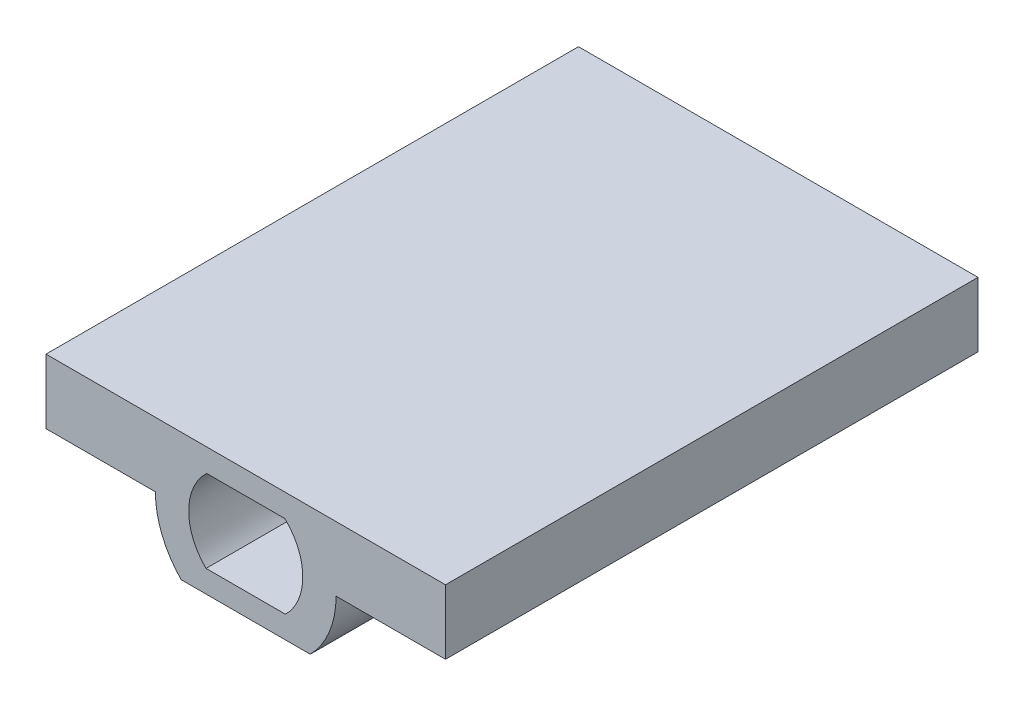
from build123d import *

# Parameters (mm, degrees)
BOSS_EXTRUDE1_DEPTH = 101.6


with BuildPart() as part:
    # Sketch1 → Boss-Extrude1 (new body)
    with BuildSketch(Plane.XY):
        with BuildLine():
            Line((-38.109310446, 0), (-38.109310446, 12.319))
            Line((-38.109310446, 12.319), (38.11716556, 12.319))
            Line((38.11716556, 12.319), (38.11716556, 0))
            Line((38.11716556, 0), (17.238227932, 0))
            ThreePointArc((17.238227932, 0), (15.959298514, -6.515926117), (12.312281561, -12.065))
            Line((12.312281561, -12.065), (12.05814004, -12.065))
            Line((12.05814004, -12.065), (-12.05814004, -12.065))
            Line((-12.05814004, -12.065), (-12.312281561, -12.065))
            ThreePointArc((-12.312281561, -12.065), (-15.959298514, -6.515926117), (-17.238227932, 0))
            Line((-17.238227932, 0), (-38.109310446, 0))
        make_face()
        with BuildLine():
            Line((-7.459501807, 7.931540852), (7.459501807, 7.931540852))
            ThreePointArc((7.459501807, 7.931540852), (10.887932539, 0.08020301), (7.575537086, -7.820789305))
            Line((7.575537086, -7.820789305), (-7.575537086, -7.820789305))
            ThreePointArc((-7.575537086, -7.820789305), (-10.887932539, 0.08020301), (-7.459501807, 7.931540852))
        make_face(mode=Mode.SUBTRACT)
    extrude(amount=-BOSS_EXTRUDE1_DEPTH)


solid = part.part
